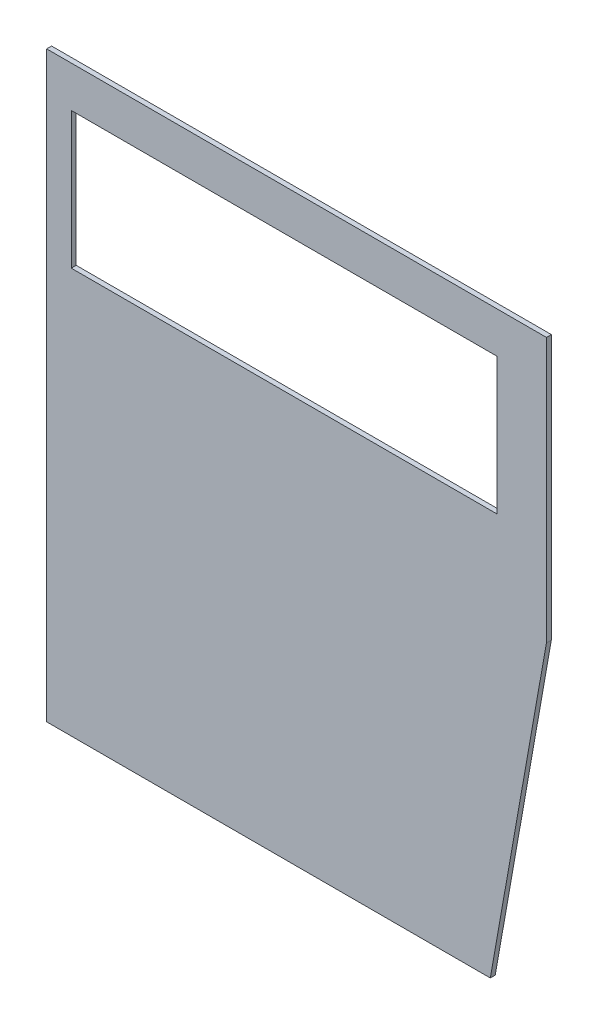
from build123d import *

# Parameters (mm, degrees)
SKETCH1_W           = 259.398086837
SKETCH1_H           = 83.19083402
BOSS_EXTRUDE1_DEPTH = 3


with BuildPart() as part:
    # Sketch1 → Boss-Extrude1 (new body)
    with BuildSketch(Plane.XY):
        Polygon((816.17673453, 30), (1086.394904374, 30), (1120.574821367, 223.843941842), (1120.574821367, 385), (816.17673453, 385), align=None)
        with Locations((960.875777949, 318.40458299)):
            Rectangle(SKETCH1_W, SKETCH1_H, mode=Mode.SUBTRACT)
    extrude(amount=-BOSS_EXTRUDE1_DEPTH)


solid = part.part
